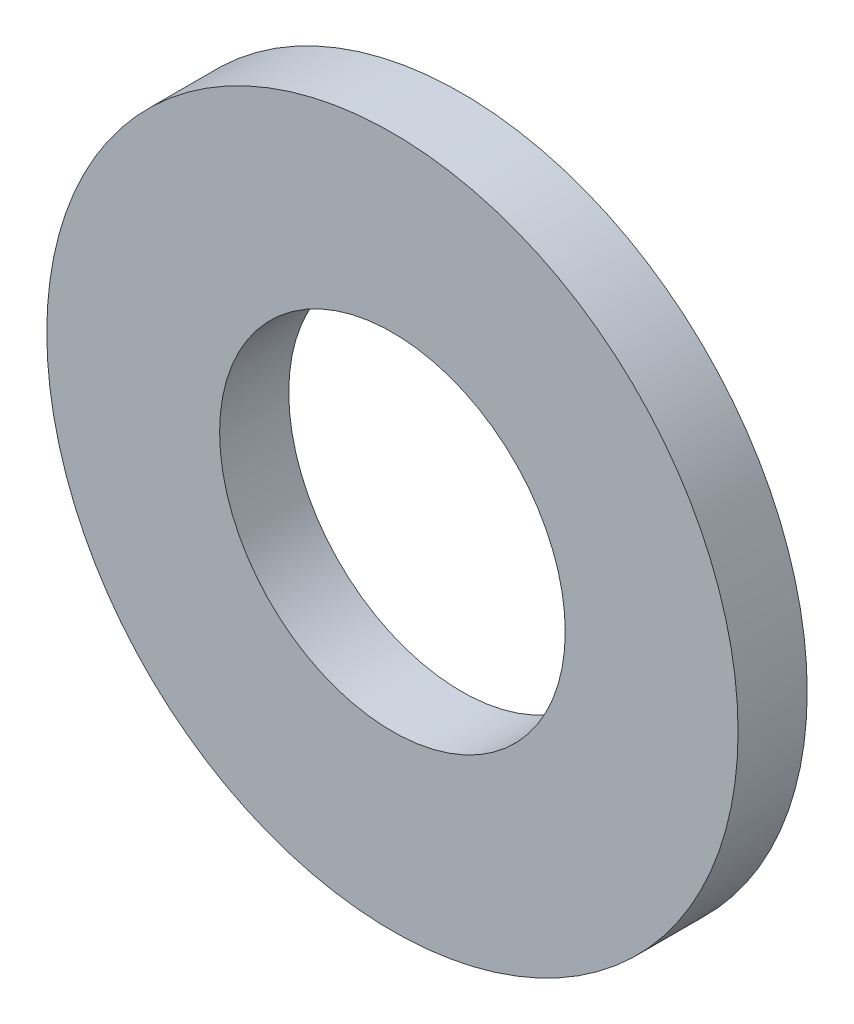
from build123d import *

# Parameters (mm, degrees)
SKETCH1_R           = 7.9375
SKETCH1_R_2         = 3.96875
BOSS_EXTRUDE1_DEPTH = 1.5875


with BuildPart() as part:
    # Sketch1 → Boss-Extrude1 (new body)
    with BuildSketch(Plane.XY):
        Circle(SKETCH1_R)
        Circle(SKETCH1_R_2, mode=Mode.SUBTRACT)
    extrude(amount=BOSS_EXTRUDE1_DEPTH)


solid = part.part
